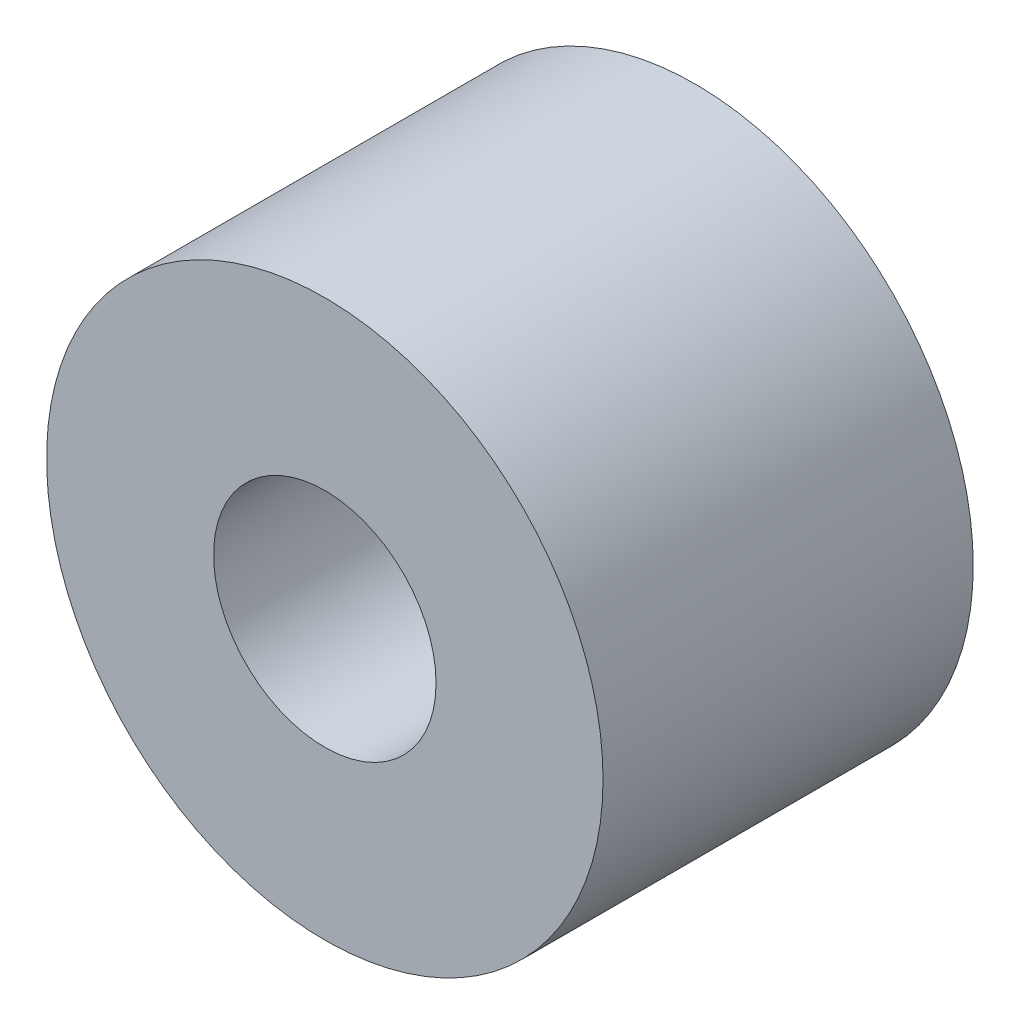
from build123d import *

# Parameters (mm, degrees)
SZKIC2_R                    = 953
SZKIC2_R_2                  = 381
DODANIE_WYCI_GNI_CIE1_DEPTH = 1268


with BuildPart() as part:
    # Szkic2 → Dodanie-wyciągnięcie1 (new body)
    with BuildSketch(Plane.XY):
        Circle(SZKIC2_R)
        Circle(SZKIC2_R_2, mode=Mode.SUBTRACT)
    extrude(amount=DODANIE_WYCI_GNI_CIE1_DEPTH)


solid = part.part
